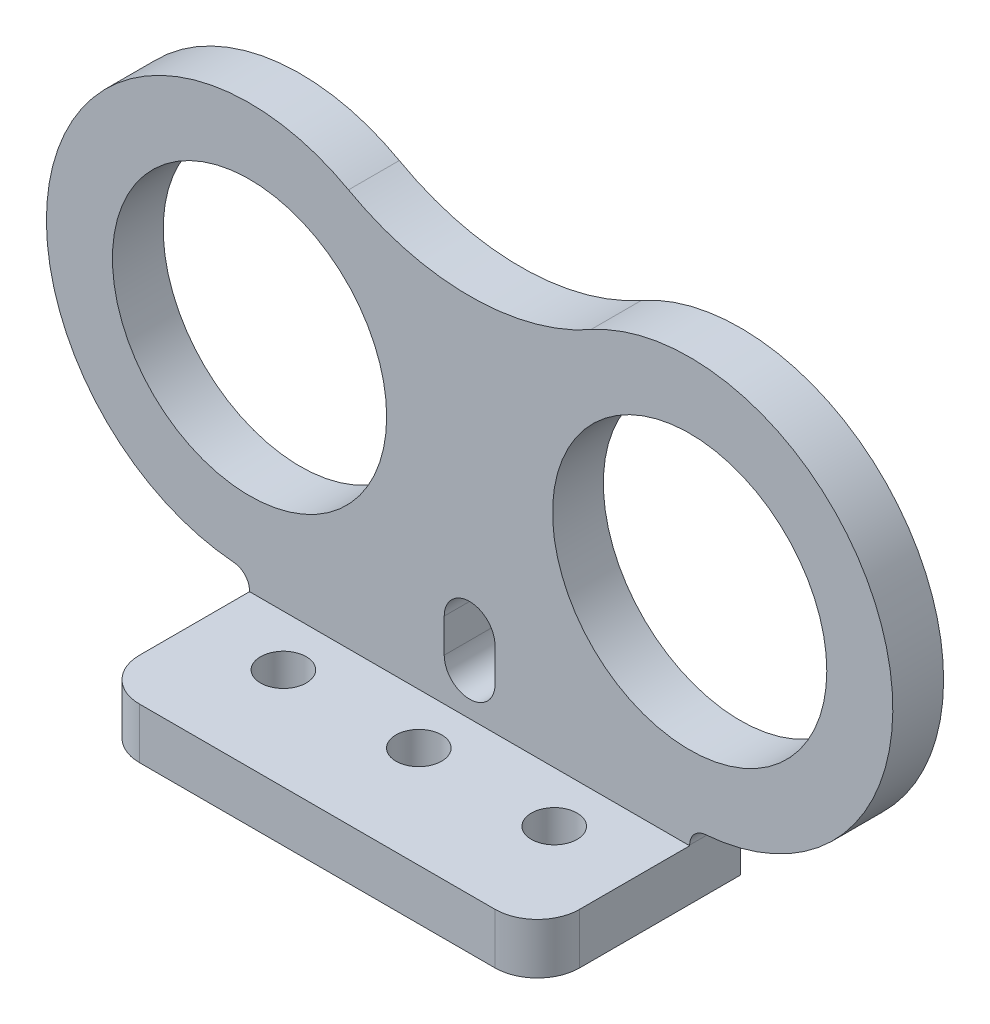
from build123d import *

# Parameters (mm, degrees)
SKETCH1_R           = 8.1
BOSS_EXTRUDE1_DEPTH = 3
SKETCH3_R           = 1.35
BOSS_EXTRUDE2_DEPTH = 3


with BuildPart() as part:
    # Sketch1 → Boss-Extrude1 (new body)
    with BuildSketch(Plane.XY):
        with BuildLine():
            Line((-13, 3.038518603), (-13, 0))
            Line((-13, 0), (13, 0))
            Line((13, 0), (13, 3.038518603))
            ThreePointArc((13, 3.038518603), (13.266200614, 3.717884824), (13.923076923, 4.035555634))
            ThreePointArc((13.923076923, 4.035555634), (21.805592628, 7.847605354), (25, 16))
            ThreePointArc((25, 16), (19.076193076, 26.347940747), (7.153353716, 26.479347653))
            ThreePointArc((7.153353716, 26.479347653), (0, 24.618834191), (-7.153353716, 26.479347653))
            ThreePointArc((-7.153353716, 26.479347653), (-19.076193076, 26.347940747), (-25, 16))
            ThreePointArc((-25, 16), (-21.805592628, 7.847605354), (-13.923076923, 4.035555634))
            ThreePointArc((-13.923076923, 4.035555634), (-13.266200614, 3.717884824), (-13, 3.038518603))
        make_face()
        with BuildLine():
            ThreePointArc((-1.5, 7.5), (0, 9), (1.5, 7.5))
            Line((1.5, 7.5), (1.5, 5.5))
            ThreePointArc((1.5, 5.5), (0, 4), (-1.5, 5.5))
            Line((-1.5, 5.5), (-1.5, 7.5))
        make_face(mode=Mode.SUBTRACT)
        with Locations((-13, 16)):
            Circle(SKETCH1_R, mode=Mode.SUBTRACT)
        with Locations((13, 16)):
            Circle(SKETCH1_R, mode=Mode.SUBTRACT)
    extrude(amount=BOSS_EXTRUDE1_DEPTH)

    # Sketch3 → Boss-Extrude2 (add)
    with BuildSketch(Plane.XZ):
        with BuildLine():
            Line((-13, 3), (13, 3))
            Line((13, 3), (13, 9.5))
            ThreePointArc((13, 9.5), (12.267766953, 11.267766953), (10.5, 12))
            Line((10.5, 12), (-10.5, 12))
            ThreePointArc((-10.5, 12), (-12.267766953, 11.267766953), (-13, 9.5))
            Line((-13, 9.5), (-13, 3))
        make_face()
        with Locations((8, 6)):
            Circle(SKETCH3_R, mode=Mode.SUBTRACT)
        with Locations((-8, 6)):
            Circle(SKETCH3_R, mode=Mode.SUBTRACT)
        with Locations((0, 6)):
            Circle(SKETCH3_R, mode=Mode.SUBTRACT)
    extrude(amount=-BOSS_EXTRUDE2_DEPTH)


solid = part.part
